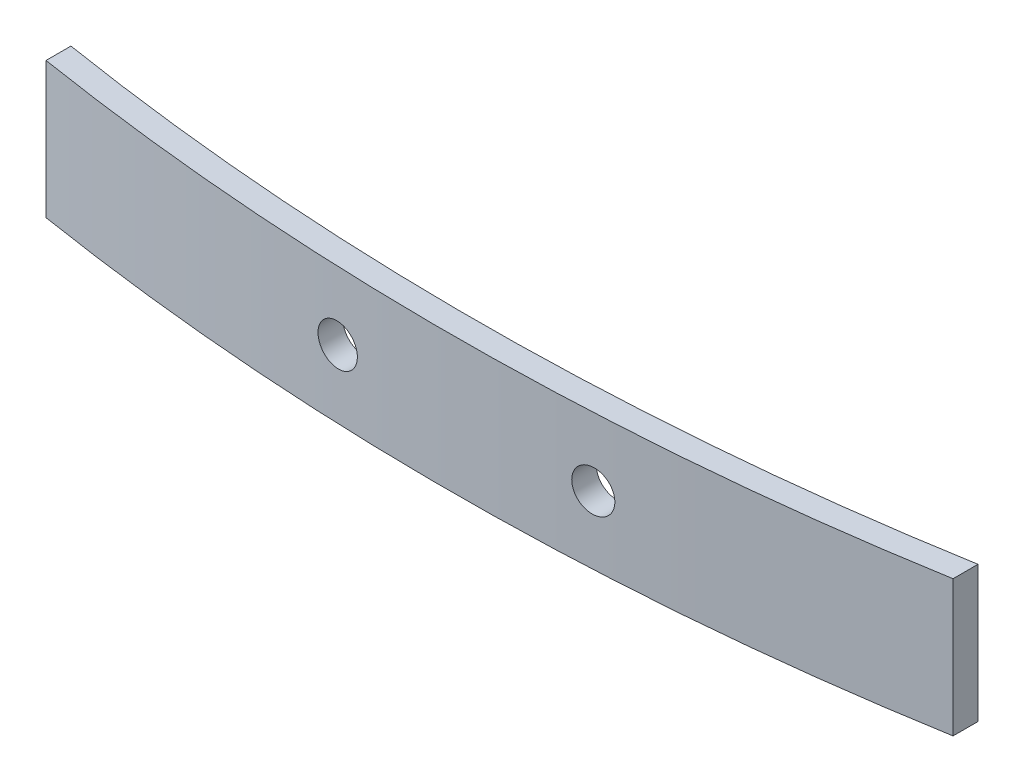
from build123d import *

# Parameters (mm, degrees)
BOSS_EXTRUDE1_DEPTH     = 8.3
SKETCH2_R               = 1.25
CUT_EXTRUDE1_DEPTH      = 5.200074126
CUT_EXTRUDE1_DEPTH_BACK = 1


with BuildPart() as part:
    # Sketch1 → Boss-Extrude1 (new body)
    with BuildSketch(Plane(origin=(0, 0, 0), x_dir=(1, 0, 0), z_dir=(0, 1, 0))):
        with BuildLine():
            Line((27.5, -0.276653737), (27.5, -1.798512845))
            ThreePointArc((27.5, -1.798512845), (0.011725116, -4.19779634), (-27.5, -2.084316151))
            Line((-27.5, -2.084316151), (-27.5, -0.56509193))
            ThreePointArc((-27.5, -0.56509193), (0.011940827, -2.697774775), (27.5, -0.276653737))
        make_face()
    extrude(amount=BOSS_EXTRUDE1_DEPTH)

    # Sketch2 → Cut-Extrude1 (cut, two sides)
    with BuildSketch(Plane.XY) as cut_extrude1_sk:
        with Locations((-7.75, 4.15)):
            Circle(SKETCH2_R)
        with Locations((7.75, 4.15)):
            Circle(SKETCH2_R)
    extrude(amount=CUT_EXTRUDE1_DEPTH, mode=Mode.SUBTRACT)
    extrude(cut_extrude1_sk.sketch, amount=-CUT_EXTRUDE1_DEPTH_BACK, mode=Mode.SUBTRACT)


solid = part.part
